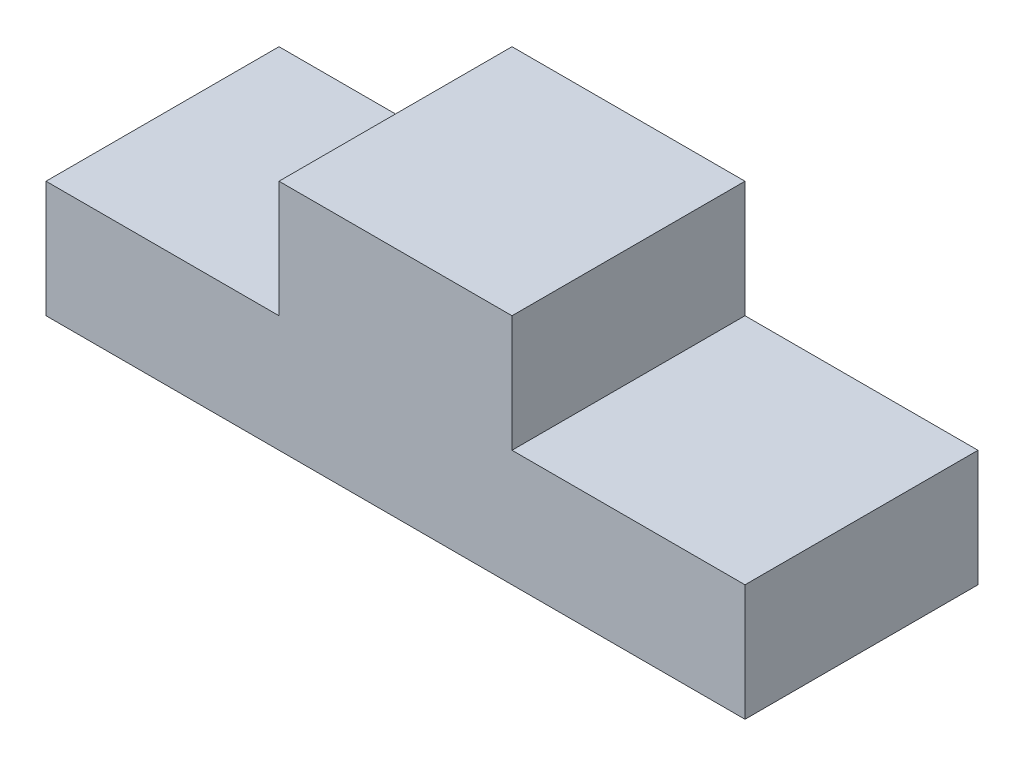
from build123d import *

# Parameters (mm, degrees)
BOSS_EXTRUDE1_DEPTH = 25.4


with BuildPart() as part:
    # Sketch1 → Boss-Extrude1 (new body)
    with BuildSketch(Plane.XY):
        Polygon((0, 12.7), (25.4, 12.7), (25.4, 25.4), (50.8, 25.4), (50.8, 12.7), (76.2, 12.7), (76.2, 0), (0, 0), align=None)
    extrude(amount=-BOSS_EXTRUDE1_DEPTH)


solid = part.part
